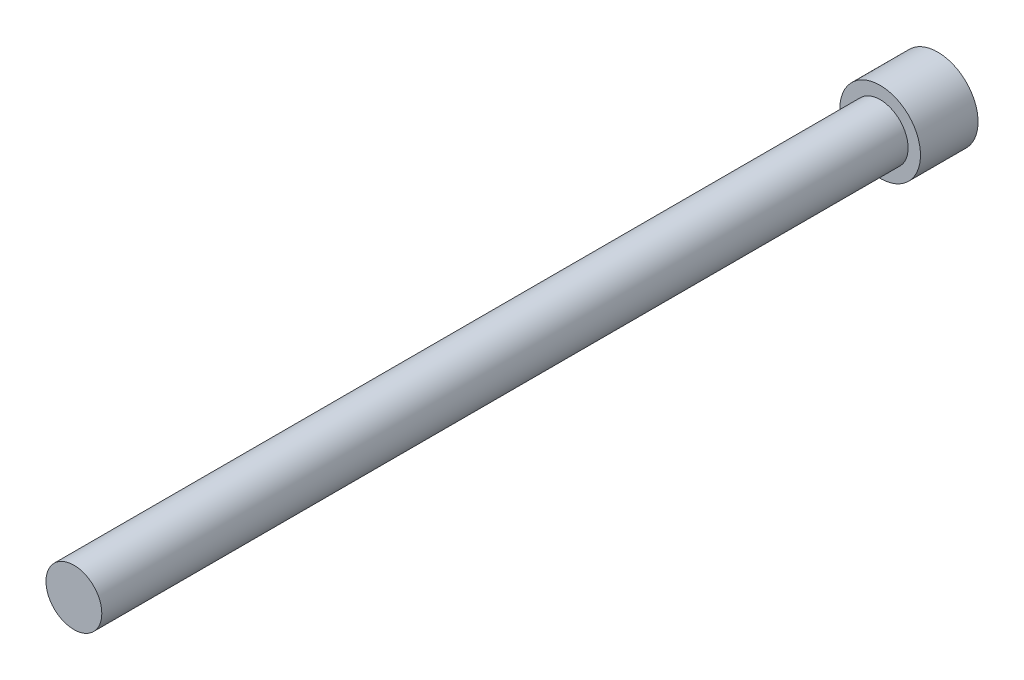
from build123d import *

# Parameters (mm, degrees)
CROQUIS1_R              = 2.425
SALIENTE_EXTRUIR1_DEPTH = 70
CROQUIS2_R              = 3.5
SALIENTE_EXTRUIR2_DEPTH = 5


with BuildPart() as part:
    # Croquis1 → Saliente-Extruir1 (new body)
    with BuildSketch(Plane.XY):
        Circle(CROQUIS1_R)
    extrude(amount=SALIENTE_EXTRUIR1_DEPTH)

    # Croquis2 → Saliente-Extruir2 (add)
    with BuildSketch(Plane(origin=(0, 0, 0), x_dir=(-1, 0, 0), z_dir=(0, 0, -1))):
        Circle(CROQUIS2_R)
    extrude(amount=SALIENTE_EXTRUIR2_DEPTH)


solid = part.part
